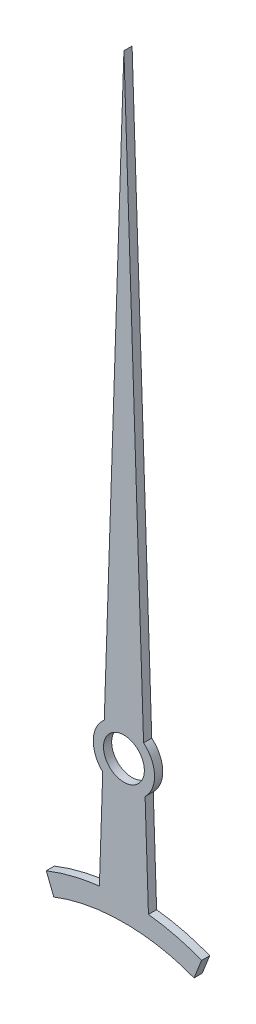
from build123d import *

# Parameters (mm, degrees)
CROQUIS1_R              = 0.75
CROQUIS1_R_2            = 0.5
SALIENTE_EXTRUIR1_DEPTH = 0.2


with BuildPart() as part:
    # Croquis1 → Saliente-Extruir1 (new body)
    with BuildSketch(Plane.XY):
        with BuildLine():
            Line((0.480813239, 0.57560284), (0, 15))
            Line((0, 15), (-0.480813239, 0.57560284))
            ThreePointArc((-0.480813239, 0.57560284), (0, 0.75), (0.480813239, 0.57560284))
        make_face()
        Circle(CROQUIS1_R)
        Circle(CROQUIS1_R_2, mode=Mode.SUBTRACT)
        with BuildLine():
            ThreePointArc((0.518076883, -0.542306503), (0, -0.75), (-0.518076883, -0.542306503))
            Line((-0.518076883, -0.542306503), (-0.6, -3))
            add(Edge.make_bspline(
                [(-0.6, -3), (-0.201744862, -2.954169047), (0.201744862, -2.954169047), (0.6, -3)],
                knots=[0.345361209, 0.345361209, 0.345361209, 0.345361209, 0.654638791, 0.654638791, 0.654638791, 0.654638791], degree=3))
            Line((0.6, -3), (0.518076883, -0.542306503))
        make_face()
        with BuildLine():
            add(Edge.make_bspline(
                [(-0.6, -3), (-0.201744862, -2.954169047), (0.201744862, -2.954169047), (0.6, -3)],
                knots=[0.345361209, 0.345361209, 0.345361209, 0.345361209, 0.654638791, 0.654638791, 0.654638791, 0.654638791], degree=3))
            add(Edge.make_bspline(
                [(-1.9, -3.324981437), (-1.482912392, -3.159505228), (-1.044719839, -3.051178082), (-0.6, -3)],
                knots=[0, 0, 0, 0, 0.345361209, 0.345361209, 0.345361209, 0.345361209], degree=3))
            Line((-1.9, -3.324981437), (-1.71561069, -3.789740065))
            add(Edge.make_bspline(
                [(-1.71561069, -3.789740065), (-0.652484196, -3.367953038), (0.652484196, -3.367953038), (1.71561069, -3.789740065)],
                knots=[0, 0, 0, 0, 1, 1, 1, 1], degree=3))
            Line((1.71561069, -3.789740065), (1.9, -3.324981437))
            add(Edge.make_bspline(
                [(0.6, -3), (1.044719839, -3.051178082), (1.482912392, -3.159505228), (1.9, -3.324981437)],
                knots=[0.654638791, 0.654638791, 0.654638791, 0.654638791, 1, 1, 1, 1], degree=3))
        make_face()
    extrude(amount=SALIENTE_EXTRUIR1_DEPTH)


solid = part.part
